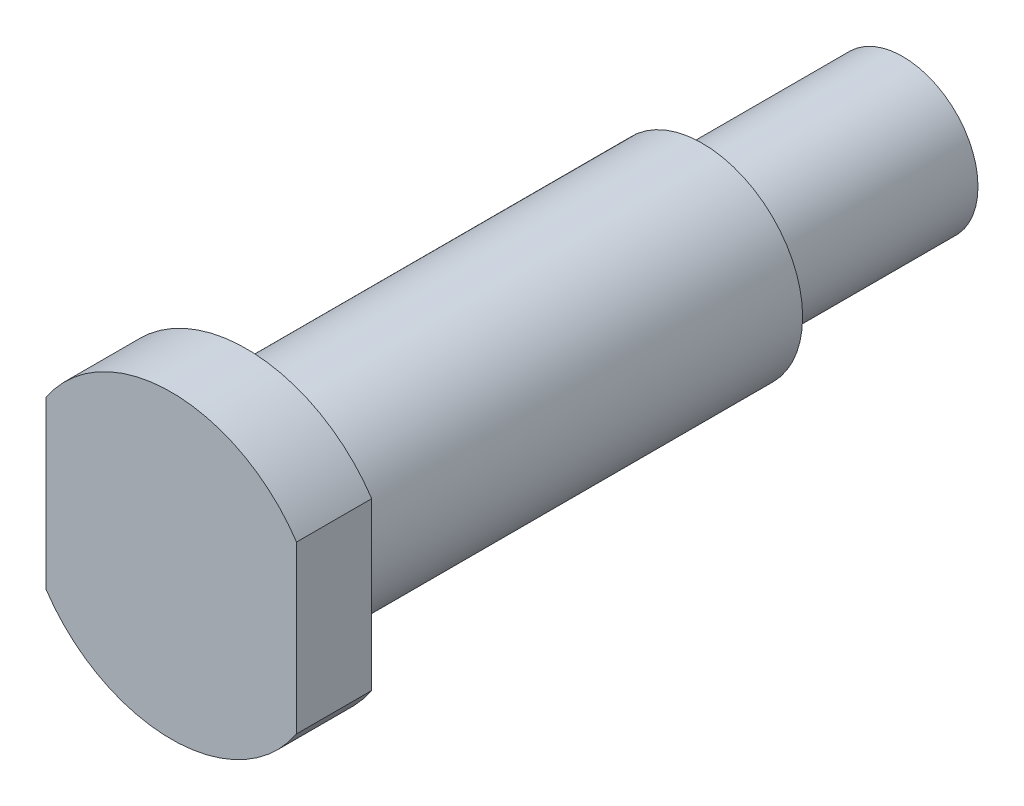
from build123d import *

# Parameters (mm, degrees)
SKETCH_3_OUTSIDE_W   = 20.754
SKETCH_3_OUTSIDE_H   = 20.754
SKETCH_3_OUTSIDE_W_2 = 10
SKETCH_3_OUTSIDE_H_2 = 14.97891863
CUT_EXTRUDE_1_DEPTH  = 10


with BuildPart() as part:
    # 草图2 → 旋转1 (revolve)
    with BuildSketch(Plane(origin=(0, 0, 0), x_dir=(0, 0, -1), z_dir=(1, 0, 0))):
        Polygon((0, 0), (0, 6), (3, 6), (3, 4), (21.2, 4), (21.2, 3), (29.2, 3), (29.2, 0), align=None)
    revolve(axis=Axis((0, 0, 0), (0, 0, -1)))

    # 草图3 outside → 切除-拉伸1 (cut)
    with BuildSketch(Plane.XY):
        Rectangle(SKETCH_3_OUTSIDE_W, SKETCH_3_OUTSIDE_H)
        Rectangle(SKETCH_3_OUTSIDE_W_2, SKETCH_3_OUTSIDE_H_2, mode=Mode.SUBTRACT)
    extrude(amount=-CUT_EXTRUDE_1_DEPTH, mode=Mode.SUBTRACT)


solid = part.part
